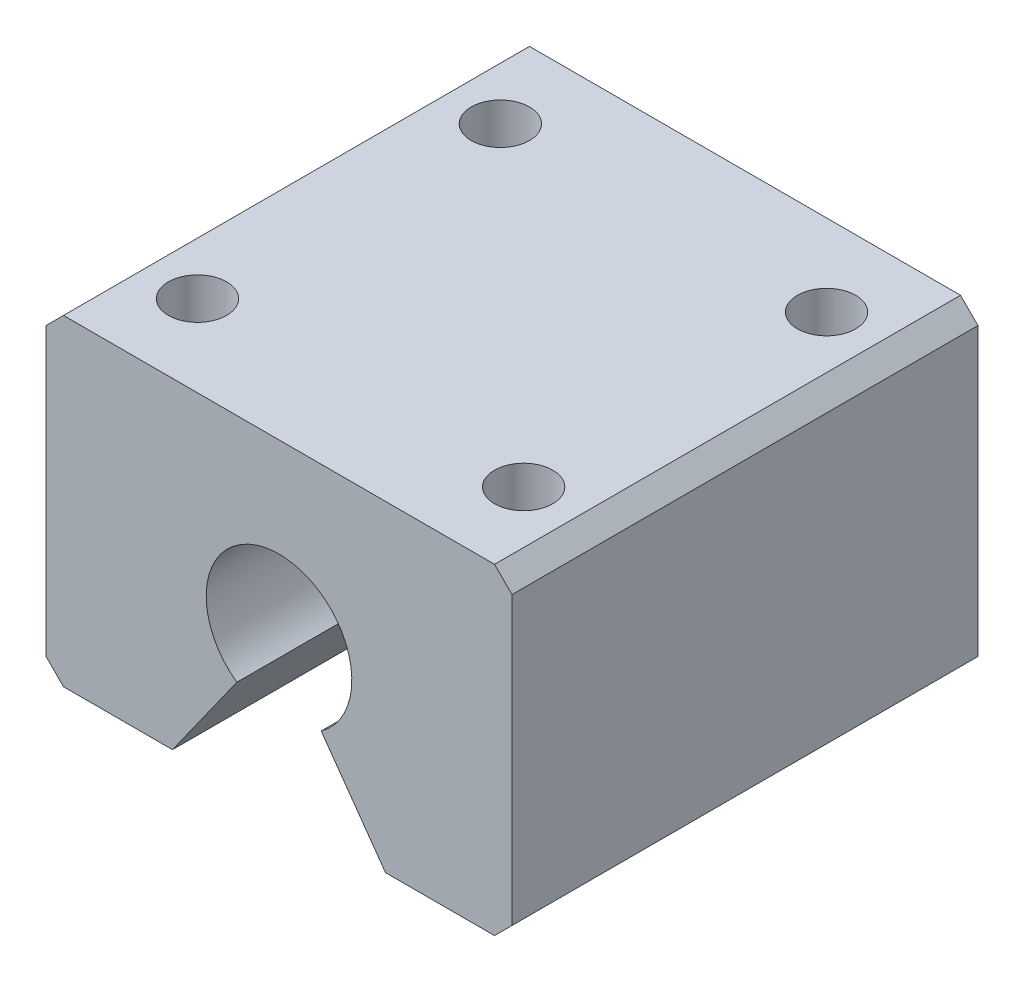
from build123d import *

# Parameters (mm, degrees)
SKETCH1_W           = 40
SKETCH1_H           = 40
BOSS_EXTRUDE1_DEPTH = 27.6
CUT_EXTRUDE1_DEPTH  = 41
SKETCH3_R           = 2.5
CUT_EXTRUDE2_DEPTH  = 14.6
CHAMFER1_SIZE       = 1.5


with BuildPart() as part:
    # Sketch1 → Boss-Extrude1 (new body)
    with BuildSketch(Plane(origin=(0, 0, 0), x_dir=(1, 0, 0), z_dir=(0, 1, 0))):
        Rectangle(SKETCH1_W, SKETCH1_H)
    extrude(amount=BOSS_EXTRUDE1_DEPTH)

    # Sketch2 → Cut-Extrude1 (cut, through all)
    with BuildSketch(Plane.XY.offset(20)):
        with BuildLine():
            Line((9.141218295, 0), (-9.141218295, 0))
            Line((-9.141218295, 0), (-3.619707233, 7.772105397))
            ThreePointArc((-3.619707233, 7.772105397), (0, 19.117222623), (3.619707233, 7.772105397))
            Line((3.619707233, 7.772105397), (9.141218295, 0))
        make_face()
    extrude(amount=-CUT_EXTRUDE1_DEPTH, mode=Mode.SUBTRACT)

    # Sketch3 → Cut-Extrude2 (cut)
    with BuildSketch(Plane(origin=(0, 27.6, 0), x_dir=(1, 0, 0), z_dir=(0, 1, 0))):
        with Locations((-14, 13)):
            Circle(SKETCH3_R)
        with Locations((14, 13)):
            Circle(SKETCH3_R)
        with Locations((14, -13)):
            Circle(SKETCH3_R)
        with Locations((-14, -13)):
            Circle(SKETCH3_R)
    extrude(amount=-CUT_EXTRUDE2_DEPTH, mode=Mode.SUBTRACT)

    # Chamfer1
    chamfer1_edges = [part.edges().sort_by_distance(p)[0] for p in [
        (-20, 27.6, 0),
        (20, 27.6, 0),
        (-20, 0, 0),
        (20, 0, 0),
    ]]
    chamfer(chamfer1_edges, length=CHAMFER1_SIZE)


solid = part.part
